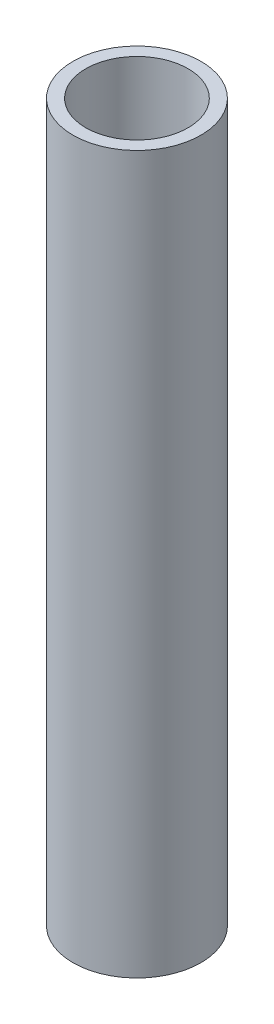
from build123d import *

# Parameters (mm, degrees)
CROQUIS1_R              = 12.5
CROQUIS1_R_2            = 10
SALIENTE_EXTRUIR1_DEPTH = 70


with BuildPart() as part:
    # Croquis1 → Saliente-Extruir1 (new body, symmetric)
    with BuildSketch(Plane(origin=(0, 0, 0), x_dir=(1, 0, 0), z_dir=(0, 1, 0))):
        Circle(CROQUIS1_R)
        Circle(CROQUIS1_R_2, mode=Mode.SUBTRACT)
    extrude(amount=SALIENTE_EXTRUIR1_DEPTH, both=True)


solid = part.part
